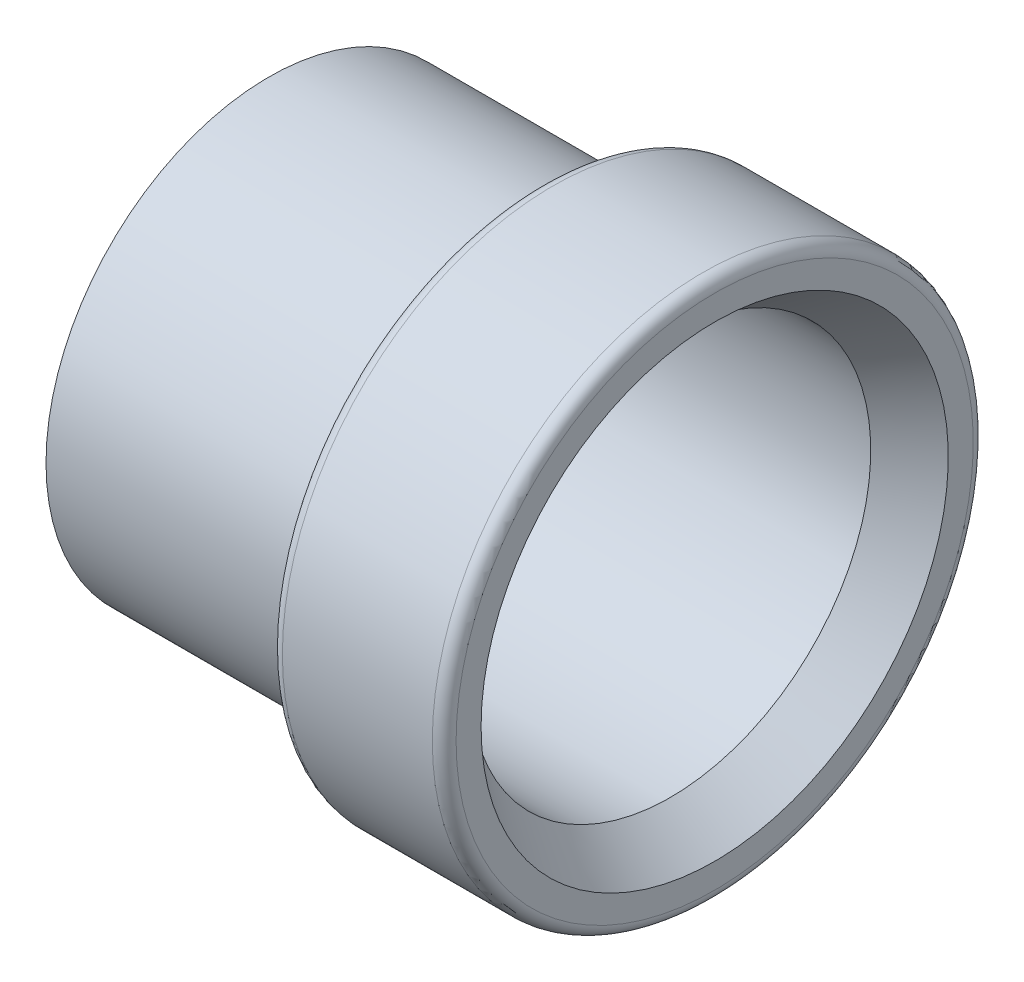
from build123d import *


with BuildPart() as part:
    # Sketch1 → Revolve1 (revolve)
    with BuildSketch(Plane.XY):
        with BuildLine():
            Line((-7.1374, 6.4135), (5.721708584, 6.4135))
            Line((5.721708584, 6.4135), (7.1374, 7.4803))
            Line((7.1374, 7.4803), (7.1374, 8.2804))
            ThreePointArc((7.1374, 8.2804), (7.025807684, 8.549807684), (6.7564, 8.6614))
            Line((6.7564, 8.6614), (1.9558, 8.6614))
            ThreePointArc((1.9558, 8.6614), (1.686392316, 8.549807684), (1.5748, 8.2804))
            Line((1.5748, 8.2804), (1.5748, 7.1374))
            Line((1.5748, 7.1374), (-7.1374, 7.1374))
            Line((-7.1374, 7.1374), (-7.1374, 6.4135))
        make_face()
    revolve(axis=Axis((-7.1374, 0, 0), (1, 0, 0)))


solid = part.part
